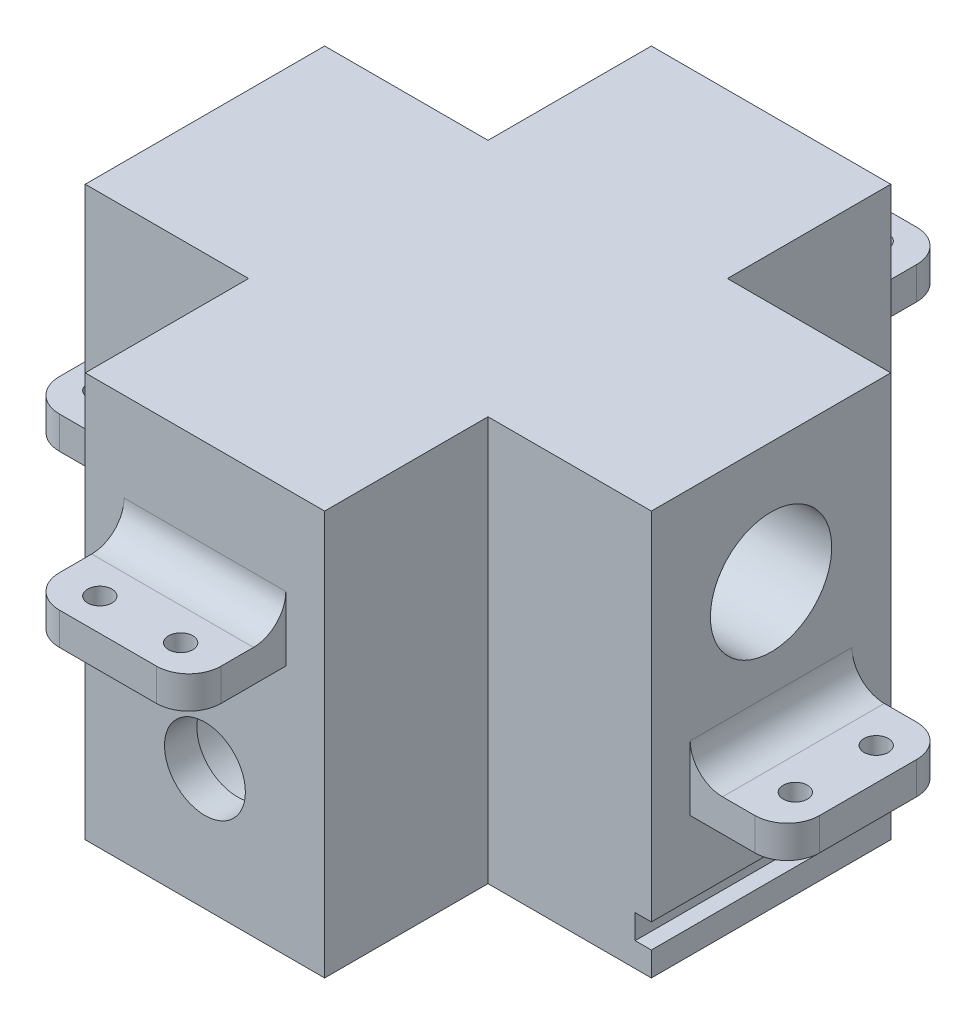
from build123d import *

# Parameters (mm, degrees)
ESQUISSE1_W              = 70
ESQUISSE1_H              = 50
BOSS_EXTRU_1_DEPTH       = 70
ESQUISSE2_R              = 7.5
ENL_V_MAT_EXTRU_1_DEPTH  = 71
ESQUISSE3_R              = 7.5
ENL_V_MAT_EXTRU_2_DEPTH  = 71
ESQUISSE4_W              = 20.2
ESQUISSE4_H              = 20.2
ENL_V_MAT_EXTRU_3_DEPTH  = 51
ESQUISSE7_R              = 11.73674641
ESQUISSE7_R_2            = 5
BOSS_EXTRU_3_DEPTH       = 4
ESQUISSE8_R              = 12.196693844
ESQUISSE8_R_2            = 5
BOSS_EXTRU_4_DEPTH       = 4
ESQUISSE9_W              = 2
ESQUISSE9_H              = 3
ENL_V_MAT_EXTRU_4_DEPTH  = 50.8
ESQUISSE10_W             = 2
ESQUISSE10_H             = 3
ENL_V_MAT_EXTRU_5_DEPTH  = 50.8
ESQUISSE11_W             = 2
ESQUISSE11_H             = 3
ENL_V_MAT_EXTRU_6_DEPTH  = 50.8
ESQUISSE12_W             = 20
ESQUISSE12_H             = 4
BOSS_EXTRU_5_DEPTH       = 12
ESQUISSE13_R             = 1.5
ENL_V_MAT_EXTRU_7_DEPTH  = 36
CONG_1_R                 = 4
ESQUISSE14_W             = 20
ESQUISSE14_H             = 4
BOSS_EXTRU_6_DEPTH       = 12
ESQUISSE15_R             = 1.5
ENL_V_MAT_EXTRU_8_DEPTH  = 36
CONG_3_R                 = 4
ESQUISSE16_W             = 20
ESQUISSE16_H             = 4
BOSS_EXTRU_7_DEPTH       = 12
ESQUISSE17_R             = 1.5
ENL_V_MAT_EXTRU_9_DEPTH  = 20
CONG_4_R                 = 4
ESQUISSE18_W             = 20
ESQUISSE18_H             = 4
BOSS_EXTRU_8_DEPTH       = 12
ESQUISSE19_R             = 1.5
ENL_V_MAT_EXTRU_10_DEPTH = 20
CONG_5_R                 = 4
CONG_6_R                 = 4


with BuildPart() as part:
    # Esquisse1 → Boss.-Extru.1 (new body)
    with BuildSketch(Plane(origin=(0, 0, 0), x_dir=(0, 0, -1), z_dir=(1, 0, 0))):
        with Locations((35, 25)):
            Rectangle(ESQUISSE1_W, ESQUISSE1_H)
    extrude(amount=BOSS_EXTRU_1_DEPTH)

    # Esquisse2 → Enlèv. mat.-Extru.1 (cut, through all)
    with BuildSketch(Plane.XY):
        with Locations((35, 15)):
            Circle(ESQUISSE2_R)
    extrude(amount=-ENL_V_MAT_EXTRU_1_DEPTH, mode=Mode.SUBTRACT)

    # Esquisse3 → Enlèv. mat.-Extru.2 (cut, through all)
    with BuildSketch(Plane.ZY):
        with Locations((-35, 35)):
            Circle(ESQUISSE3_R)
    extrude(amount=-ENL_V_MAT_EXTRU_2_DEPTH, mode=Mode.SUBTRACT)

    # Esquisse4 → Enlèv. mat.-Extru.3 (cut, through all)
    with BuildSketch(Plane.XZ):
        with Locations((10.1, -59.9)):
            Rectangle(ESQUISSE4_W, ESQUISSE4_H)
        with Locations((10.1, -10.1)):
            Rectangle(ESQUISSE4_W, ESQUISSE4_H)
        with Locations((59.9, -10.1)):
            Rectangle(ESQUISSE4_W, ESQUISSE4_H)
        with Locations((59.9, -59.9)):
            Rectangle(ESQUISSE4_W, ESQUISSE4_H)
    extrude(amount=-ENL_V_MAT_EXTRU_3_DEPTH, mode=Mode.SUBTRACT)

    # Esquisse7 → Boss.-Extru.3 (add)
    with BuildSketch(Plane.XY):
        with Locations((35, 15)):
            Circle(ESQUISSE7_R)
        with Locations((35, 15)):
            Circle(ESQUISSE7_R_2, mode=Mode.SUBTRACT)
    extrude(amount=-BOSS_EXTRU_3_DEPTH)

    # Esquisse8 → Boss.-Extru.4 (add)
    with BuildSketch(Plane.ZY):
        with Locations((-35, 35)):
            Circle(ESQUISSE8_R)
        with Locations((-35, 35)):
            Circle(ESQUISSE8_R_2, mode=Mode.SUBTRACT)
    extrude(amount=-BOSS_EXTRU_4_DEPTH)

    # Esquisse9 → Enlèv. mat.-Extru.4 (cut, through all)
    with BuildSketch(Plane.ZY.offset(-20.2)):
        with Locations((-69, 4.5)):
            Rectangle(ESQUISSE9_W, ESQUISSE9_H)
    extrude(amount=-ENL_V_MAT_EXTRU_4_DEPTH, mode=Mode.SUBTRACT)

    # Esquisse10 → Enlèv. mat.-Extru.5 (cut, through all)
    with BuildSketch(Plane(origin=(0, 0, -49.8), x_dir=(-1, 0, 0), z_dir=(0, 0, -1))):
        with Locations((-1, 4.5)):
            Rectangle(ESQUISSE10_W, ESQUISSE10_H)
    extrude(amount=-ENL_V_MAT_EXTRU_5_DEPTH, mode=Mode.SUBTRACT)

    # Esquisse11 → Enlèv. mat.-Extru.6 (cut, through all)
    with BuildSketch(Plane(origin=(0, 0, -49.8), x_dir=(-1, 0, 0), z_dir=(0, 0, -1))):
        with Locations((-69, 4.5)):
            Rectangle(ESQUISSE11_W, ESQUISSE11_H)
    extrude(amount=-ENL_V_MAT_EXTRU_6_DEPTH, mode=Mode.SUBTRACT)

    # Esquisse12 → Boss.-Extru.5 (add)
    with BuildSketch(Plane.ZY):
        with Locations((-35, 17)):
            Rectangle(ESQUISSE12_W, ESQUISSE12_H)
    extrude(amount=BOSS_EXTRU_5_DEPTH)

    # Esquisse13 → Enlèv. mat.-Extru.7 (cut, through all)
    with BuildSketch(Plane.XZ.offset(-15)):
        with Locations(Location((-8, -30, 0), (0, 0, 270))):  # turned: the seam where the file's is
            Circle(ESQUISSE13_R)
        with Locations(Location((-8, -40, 0), (0, 0, 270))):  # turned: the seam where the file's is
            Circle(ESQUISSE13_R)
    extrude(amount=-ENL_V_MAT_EXTRU_7_DEPTH, mode=Mode.SUBTRACT)

    # Congé1
    cong_1_edges = [part.edges().sort_by_distance(p)[0] for p in [
        (-12, 17, -25),
        (-12, 17, -45),
    ]]
    fillet(cong_1_edges, radius=CONG_1_R)

    # Esquisse14 → Boss.-Extru.6 (add)
    with BuildSketch(Plane(origin=(70, 0, 0), x_dir=(0, 0, -1), z_dir=(1, 0, 0))):
        with Locations((35, 17)):
            Rectangle(ESQUISSE14_W, ESQUISSE14_H)
    extrude(amount=BOSS_EXTRU_6_DEPTH)

    # Esquisse15 → Enlèv. mat.-Extru.8 (cut, through all)
    with BuildSketch(Plane.XZ.offset(-15)):
        with Locations(Location((78, -40, 0), (0, 0, 270))):  # turned: the seam where the file's is
            Circle(ESQUISSE15_R)
        with Locations(Location((78, -30, 0), (0, 0, 270))):  # turned: the seam where the file's is
            Circle(ESQUISSE15_R)
    extrude(amount=-ENL_V_MAT_EXTRU_8_DEPTH, mode=Mode.SUBTRACT)

    # Congé3
    cong_3_edges = [part.edges().sort_by_distance(p)[0] for p in [
        (82, 17, -45),
        (82, 17, -25),
    ]]
    fillet(cong_3_edges, radius=CONG_3_R)

    # Esquisse16 → Boss.-Extru.7 (add)
    with BuildSketch(Plane.XY):
        with Locations((35, 33)):
            Rectangle(ESQUISSE16_W, ESQUISSE16_H)
    extrude(amount=BOSS_EXTRU_7_DEPTH)

    # Esquisse17 → Enlèv. mat.-Extru.9 (cut, through all)
    with BuildSketch(Plane.XZ.offset(-31)):
        with Locations((40, 8)):
            Circle(ESQUISSE17_R)
        with Locations((30, 8)):
            Circle(ESQUISSE17_R)
    extrude(amount=-ENL_V_MAT_EXTRU_9_DEPTH, mode=Mode.SUBTRACT)

    # Congé4
    cong_4_edges = [part.edges().sort_by_distance(p)[0] for p in [
        (45, 33, 12),
        (25, 33, 12),
    ]]
    fillet(cong_4_edges, radius=CONG_4_R)

    # Esquisse18 → Boss.-Extru.8 (add)
    with BuildSketch(Plane(origin=(0, 0, -70), x_dir=(-1, 0, 0), z_dir=(0, 0, -1))):
        with Locations((-35, 33)):
            Rectangle(ESQUISSE18_W, ESQUISSE18_H)
    extrude(amount=BOSS_EXTRU_8_DEPTH)

    # Esquisse19 → Enlèv. mat.-Extru.10 (cut, through all)
    with BuildSketch(Plane.XZ.offset(-31)):
        with Locations((30, -78)):
            Circle(ESQUISSE19_R)
        with Locations((40, -78)):
            Circle(ESQUISSE19_R)
    extrude(amount=-ENL_V_MAT_EXTRU_10_DEPTH, mode=Mode.SUBTRACT)

    # Congé5
    cong_5_edges = [part.edges().sort_by_distance(p)[0] for p in [
        (25, 33, -82),
        (45, 33, -82),
    ]]
    fillet(cong_5_edges, radius=CONG_5_R)

    # Congé6
    cong_6_edges = [part.edges().sort_by_distance(p)[0] for p in [
        (0, 19, -35),
        (70, 19, -35),
        (35, 35, 0),
        (35, 35, -70),
    ]]
    fillet(cong_6_edges, radius=CONG_6_R)


solid = part.part
